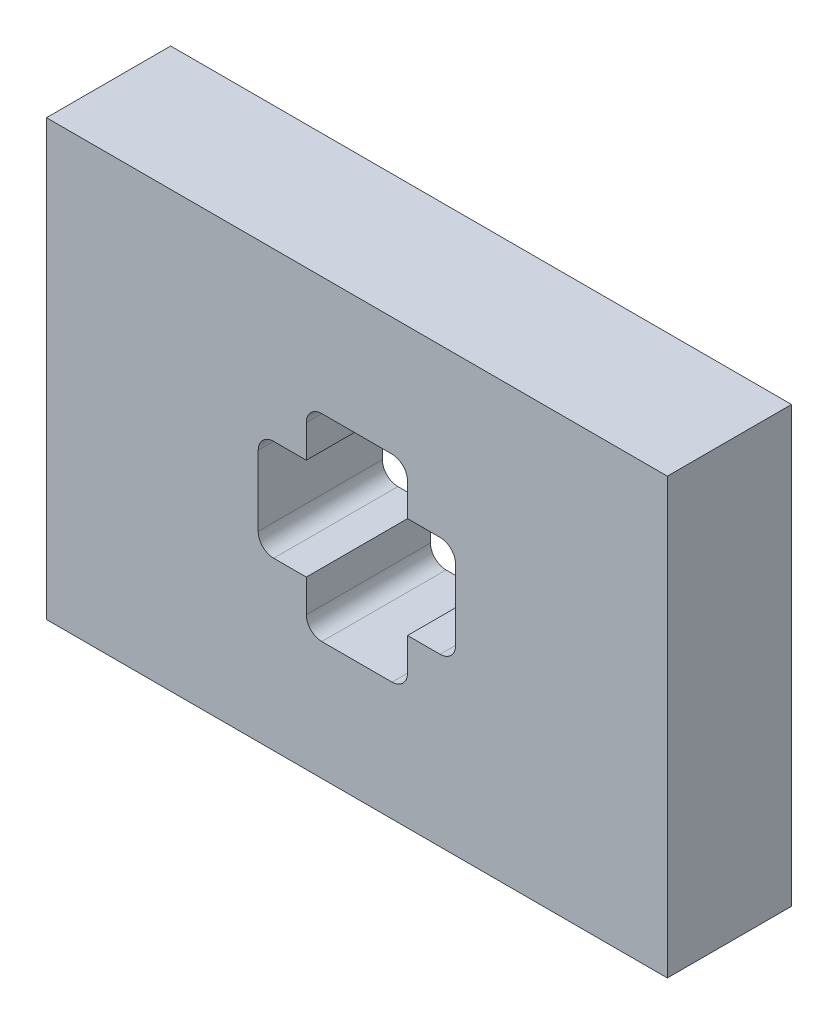
from build123d import *

# Parameters (mm, degrees)
SKETCH1_W           = 100
SKETCH1_H           = 70
BOSS_EXTRUDE1_DEPTH = 20


with BuildPart() as part:
    # Sketch1 → Boss-Extrude1 (new body)
    with BuildSketch(Plane.XY):
        Rectangle(SKETCH1_W, SKETCH1_H)
        with BuildLine():
            Line((-8.15, 13.4), (-8.15, 8.15))
            Line((-8.15, 8.15), (-13.4, 8.15))
            ThreePointArc((-13.4, 8.15), (-15.167766953, 7.417766953), (-15.9, 5.65))
            Line((-15.9, 5.65), (-15.9, -5.65))
            ThreePointArc((-15.9, -5.65), (-15.167766953, -7.417766953), (-13.4, -8.15))
            Line((-13.4, -8.15), (-8.15, -8.15))
            Line((-8.15, -8.15), (-8.15, -13.4))
            ThreePointArc((-8.15, -13.4), (-7.417766953, -15.167766953), (-5.65, -15.9))
            Line((-5.65, -15.9), (5.65, -15.9))
            ThreePointArc((5.65, -15.9), (7.417766953, -15.167766953), (8.15, -13.4))
            Line((8.15, -13.4), (8.15, -8.15))
            Line((8.15, -8.15), (13.4, -8.15))
            ThreePointArc((13.4, -8.15), (15.167766953, -7.417766953), (15.9, -5.65))
            Line((15.9, -5.65), (15.9, 5.65))
            ThreePointArc((15.9, 5.65), (15.167766953, 7.417766953), (13.4, 8.15))
            Line((13.4, 8.15), (8.15, 8.15))
            Line((8.15, 8.15), (8.15, 13.4))
            ThreePointArc((8.15, 13.4), (7.417766953, 15.167766953), (5.65, 15.9))
            Line((5.65, 15.9), (-5.65, 15.9))
            ThreePointArc((-5.65, 15.9), (-7.417766953, 15.167766953), (-8.15, 13.4))
        make_face(mode=Mode.SUBTRACT)
    extrude(amount=BOSS_EXTRUDE1_DEPTH)


solid = part.part
